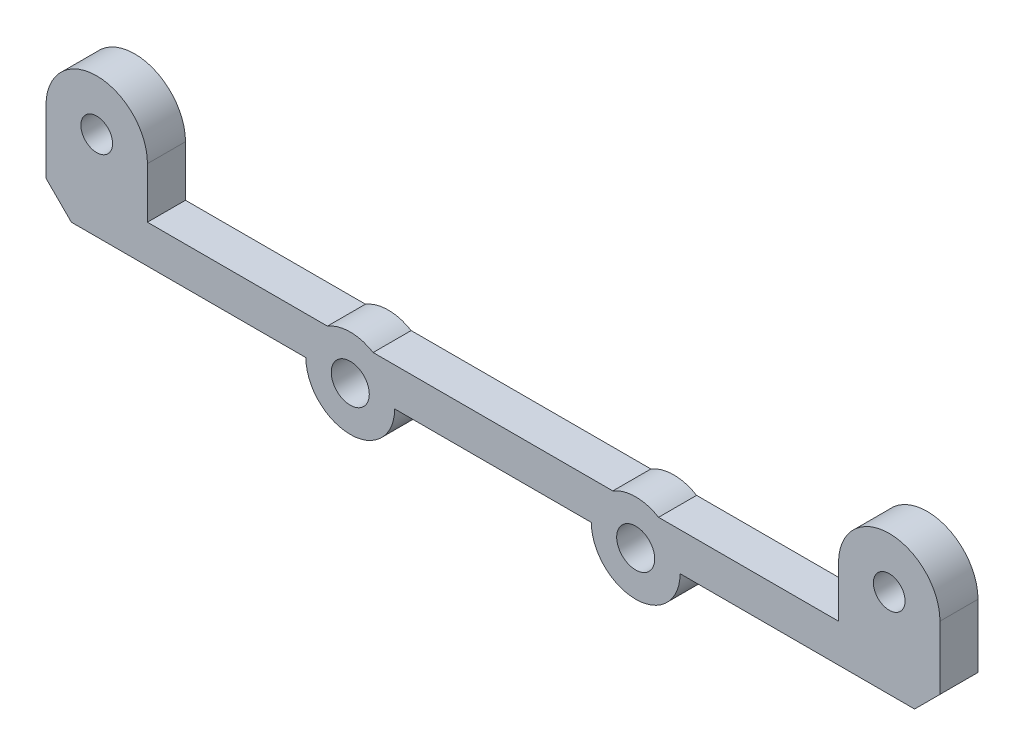
from build123d import *

# Parameters (mm, degrees)
SKETCH_1_R      = 1.5
SKETCH_1_R_2    = 1.25
EXTRUDE_2_DEPTH = 3


with BuildPart() as part:
    # 草图1 → 凸台-拉伸2 (new body)
    with BuildSketch(Plane.XY):
        with BuildLine():
            Line((3.5, 0), (19.01, 0))
            ThreePointArc((19.01, 0), (22.51, -3.5), (26.01, 0))
            Line((26.01, 0), (44.505, 0))
            Line((44.505, 0), (46.505, 2))
            Line((46.505, 2), (46.505, 7))
            ThreePointArc((46.505, 7), (42.505, 11), (38.505, 7))
            Line((38.505, 7), (38.505, 3))
            Line((38.505, 3), (24.312775638, 3))
            ThreePointArc((24.312775638, 3), (22.51, 3.5), (20.707224362, 3))
            Line((20.707224362, 3), (1.802775638, 3))
            ThreePointArc((1.802775638, 3), (0, 3.5), (-1.802775638, 3))
            Line((-1.802775638, 3), (-15.995, 3))
            Line((-15.995, 3), (-15.995, 7))
            ThreePointArc((-15.995, 7), (-19.995, 11), (-23.995, 7))
            Line((-23.995, 7), (-23.995, 2))
            Line((-23.995, 2), (-21.995, 0))
            Line((-21.995, 0), (-3.5, 0))
            ThreePointArc((-3.5, 0), (0, -3.5), (3.5, 0))
        make_face()
        with Locations((22.51, 0)):
            Circle(SKETCH_1_R, mode=Mode.SUBTRACT)
        Circle(SKETCH_1_R, mode=Mode.SUBTRACT)
        with Locations((-19.995, 7)):
            Circle(SKETCH_1_R_2, mode=Mode.SUBTRACT)
        with Locations((42.505, 7)):
            Circle(SKETCH_1_R_2, mode=Mode.SUBTRACT)
    extrude(amount=EXTRUDE_2_DEPTH)


solid = part.part
